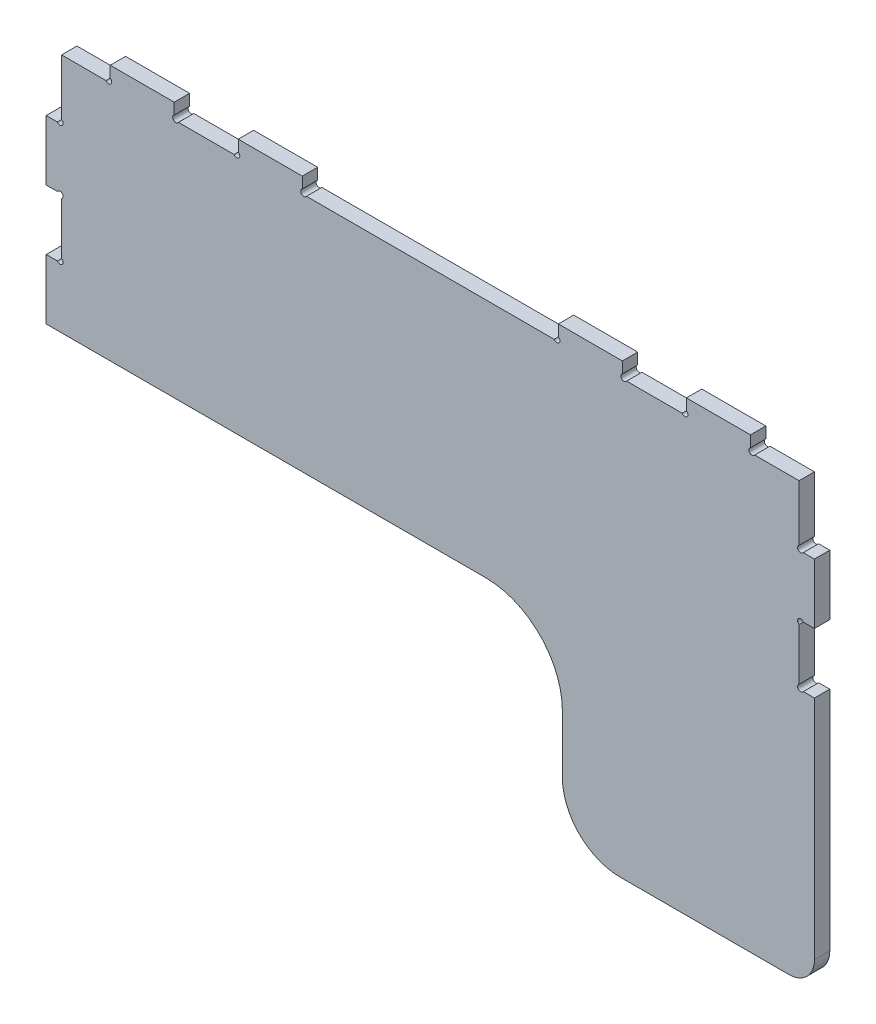
from build123d import *

# Parameters (mm, degrees)
BOSS_EXTRUDE1_DEPTH = 12


with BuildPart() as part:
    # Sketch1 → Boss-Extrude1 (new body)
    with BuildSketch(Plane.XY):
        with BuildLine():
            Line((-298.012610176, -63.342318059), (45.11407446, -63.342318059))
            ThreePointArc((45.11407446, -63.342318059), (87.540481331, -80.915911188), (105.11407446, -123.342318059))
            Line((105.11407446, -123.342318059), (105.11407446, -168.342318059))
            ThreePointArc((105.11407446, -168.342318059), (118.294269306, -200.162123213), (150.11407446, -213.342318059))
            Line((150.11407446, -213.342318059), (277.389007074, -213.342318059))
            Line((277.389007074, -213.342318059), (281.987389824, -213.342318059))
            ThreePointArc((281.987389824, -213.342318059), (296.129525447, -207.484453683), (301.987389824, -193.342318059))
            Line((301.987389824, -193.342318059), (301.987389824, -63.342318059))
            Line((301.987389824, -63.342318059), (301.987389824, -16.342318059))
            Line((301.987389824, -16.342318059), (293.265850793, -16.342318059))
            ThreePointArc((293.265850793, -16.342318059), (289.490333549, -16.839374334), (289.987389824, -13.06385709))
            Line((289.987389824, -13.06385709), (289.987389824, 27.379220972))
            ThreePointArc((289.987389824, 27.379220972), (289.490333549, 31.154738216), (293.265850793, 30.657681941))
            Line((293.265850793, 30.657681941), (301.987389824, 30.657681941))
            Line((301.987389824, 30.657681941), (301.987389824, 77.657681941))
            Line((301.987389824, 77.657681941), (293.265850793, 77.657681941))
            ThreePointArc((293.265850793, 77.657681941), (289.490333549, 77.160625666), (289.987389824, 80.93614291))
            Line((289.987389824, 80.93614291), (289.987389824, 124.657681941))
            Line((289.987389824, 124.657681941), (255.265850793, 124.657681941))
            ThreePointArc((255.265850793, 124.657681941), (251.490333549, 124.160625666), (251.987389824, 127.93614291))
            Line((251.987389824, 127.93614291), (251.987389824, 136.657681941))
            Line((251.987389824, 136.657681941), (201.987389824, 136.657681941))
            Line((201.987389824, 136.657681941), (201.987389824, 127.93614291))
            ThreePointArc((201.987389824, 127.93614291), (202.484446099, 124.160625666), (198.708928855, 124.657681941))
            Line((198.708928855, 124.657681941), (155.265850793, 124.657681941))
            ThreePointArc((155.265850793, 124.657681941), (151.490333549, 124.160625666), (151.987389824, 127.93614291))
            Line((151.987389824, 127.93614291), (151.987389824, 136.657681941))
            Line((151.987389824, 136.657681941), (101.987389824, 136.657681941))
            Line((101.987389824, 136.657681941), (101.987389824, 127.93614291))
            ThreePointArc((101.987389824, 127.93614291), (102.484446099, 124.160625666), (98.708928855, 124.657681941))
            Line((98.708928855, 124.657681941), (-94.734149207, 124.657681941))
            ThreePointArc((-94.734149207, 124.657681941), (-98.509666451, 124.160625666), (-98.012610176, 127.93614291))
            Line((-98.012610176, 127.93614291), (-98.012610176, 136.657681941))
            Line((-98.012610176, 136.657681941), (-148.012610176, 136.657681941))
            Line((-148.012610176, 136.657681941), (-148.012610176, 127.93614291))
            ThreePointArc((-148.012610176, 127.93614291), (-147.515553901, 124.160625666), (-151.291071145, 124.657681941))
            Line((-151.291071145, 124.657681941), (-194.734149207, 124.657681941))
            ThreePointArc((-194.734149207, 124.657681941), (-198.509666451, 124.160625666), (-198.012610176, 127.93614291))
            Line((-198.012610176, 127.93614291), (-198.012610176, 136.657681941))
            Line((-198.012610176, 136.657681941), (-248.012610176, 136.657681941))
            Line((-248.012610176, 136.657681941), (-248.012610176, 127.93614291))
            ThreePointArc((-248.012610176, 127.93614291), (-247.515553901, 124.160625666), (-251.291071145, 124.657681941))
            Line((-251.291071145, 124.657681941), (-286.012610176, 124.657681941))
            Line((-286.012610176, 124.657681941), (-286.012610176, 80.93614291))
            ThreePointArc((-286.012610176, 80.93614291), (-285.515553901, 77.160625666), (-289.291071145, 77.657681941))
            Line((-289.291071145, 77.657681941), (-298.012610176, 77.657681941))
            Line((-298.012610176, 77.657681941), (-298.012610176, 30.657681941))
            Line((-298.012610176, 30.657681941), (-289.291071145, 30.657681941))
            ThreePointArc((-289.291071145, 30.657681941), (-285.515553901, 31.154738216), (-286.012610176, 27.379220972))
            Line((-286.012610176, 27.379220972), (-286.012610176, -13.06385709))
            ThreePointArc((-286.012610176, -13.06385709), (-285.515553901, -16.839374334), (-289.291071145, -16.342318059))
            Line((-289.291071145, -16.342318059), (-298.012610176, -16.342318059))
            Line((-298.012610176, -16.342318059), (-298.012610176, -63.342318059))
        make_face()
    extrude(amount=BOSS_EXTRUDE1_DEPTH)


solid = part.part
